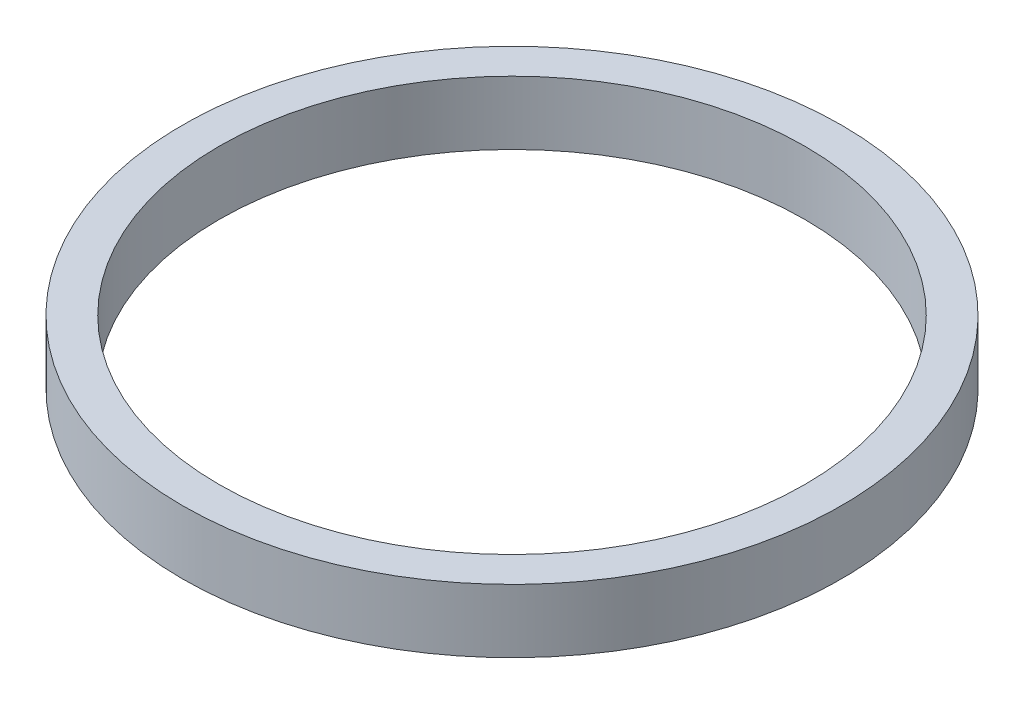
from build123d import *

# Parameters (mm, degrees)
SKETCH1_R               = 6.75
BOSS_EXTRUDE1_DEPTH     = 0.65
CUT_EXTRUDE1_DEPTH      = 10.568045777
CUT_EXTRUDE1_DEPTH_BACK = 10.568045777
SKETCH2_R               = 6


with BuildPart() as part:
    # Sketch1 → Boss-Extrude1 (new, symmetric)
    with BuildSketch(Plane(origin=(0, 0, 0), x_dir=(1, 0, 0), z_dir=(0, 1, 0))):
        Circle(SKETCH1_R)
    extrude(amount=BOSS_EXTRUDE1_DEPTH, both=True)

    # Sketch2 → Cut-Extrude1 (cut, two sides: drawn at the far end of the back side and taken through both)
    with BuildSketch(Plane(origin=(0, 0, 0), x_dir=(1, 0, 0), z_dir=(0, 1, 0)).offset(-CUT_EXTRUDE1_DEPTH_BACK)):
        Circle(SKETCH2_R)
    extrude(amount=CUT_EXTRUDE1_DEPTH + CUT_EXTRUDE1_DEPTH_BACK, mode=Mode.SUBTRACT)


solid = part.part
